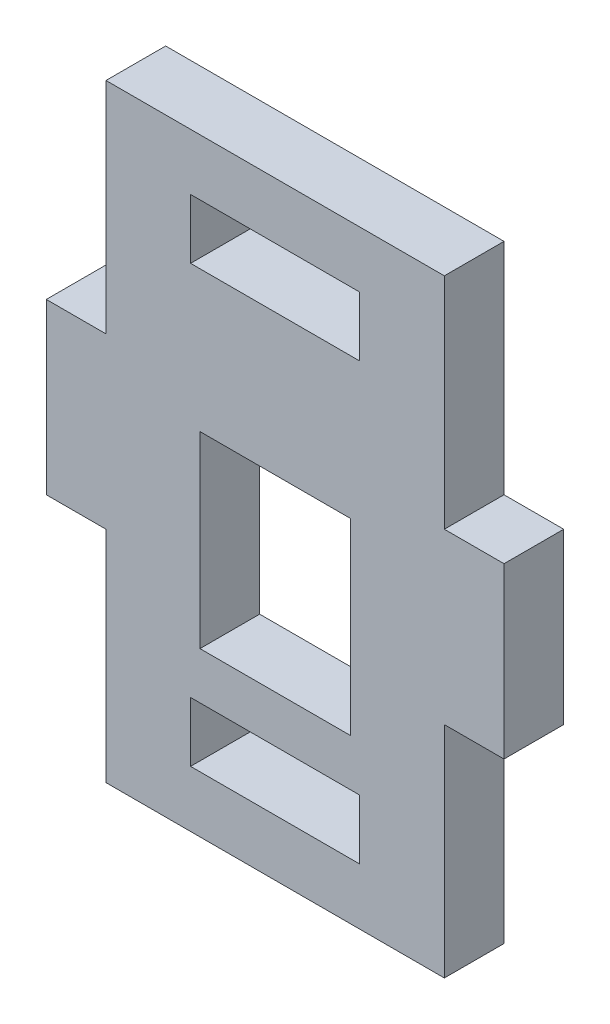
from build123d import *

# Parameters (mm, degrees)
BOSS_EXTRUDE1_DEPTH = 1.5875


with BuildPart() as part:
    # Sketch2 → Boss-Extrude1 (new body, symmetric)
    with BuildSketch(Plane.XY):
        Polygon((0, 0), (18, 0), (18, 11.675), (21.175, 11.675), (21.175, 20.675), (18, 20.675), (18, 32.35), (0, 32.35), (0, 20.675), (-3.175, 20.675), (-3.175, 11.675), (0, 11.675), align=None)
        Polygon((9, 29.35), (4.5, 29.35), (4.5, 26.175), (13.5, 26.175), (13.5, 29.35), align=None, mode=Mode.SUBTRACT)
        Polygon((13.5, 3), (9, 3), (4.5, 3), (4.5, 6.175), (13.5, 6.175), align=None, mode=Mode.SUBTRACT)
        Polygon((9, 8.675), (13, 8.675), (13, 18.675), (5, 18.675), (5, 8.675), align=None, mode=Mode.SUBTRACT)
    extrude(amount=BOSS_EXTRUDE1_DEPTH, both=True)


solid = part.part
